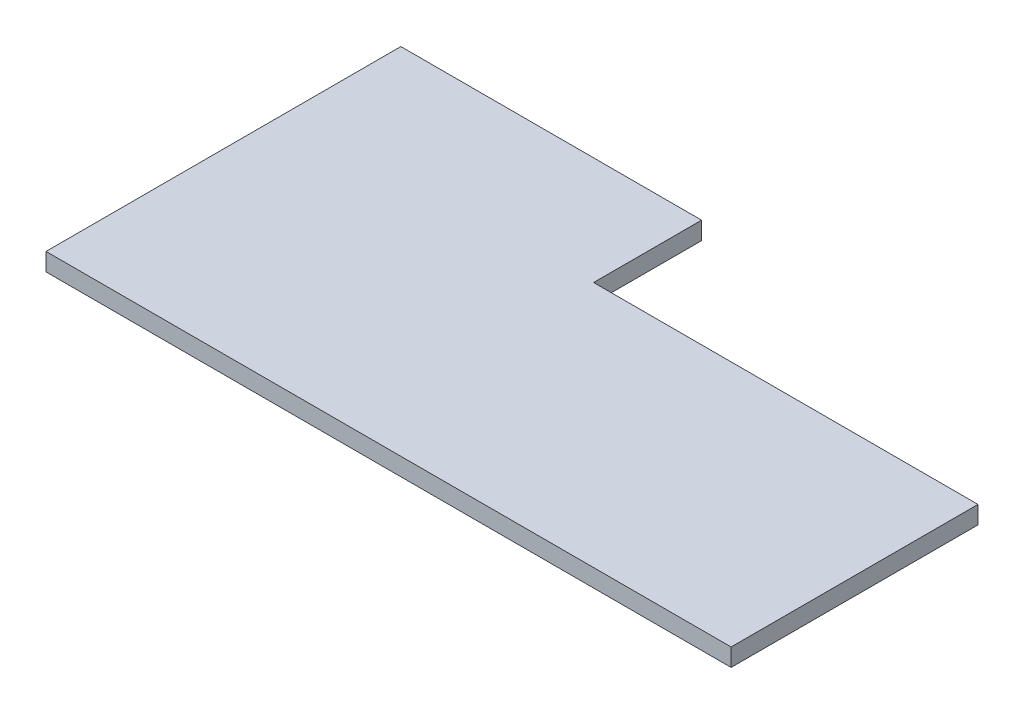
from build123d import *

# Parameters (mm, degrees)
BOSS_EXTRUDE1_DEPTH = 2.95


with BuildPart() as part:
    # Sketch1 → Boss-Extrude1 (new body)
    with BuildSketch(Plane(origin=(0, 0, 0), x_dir=(1, 0, 0), z_dir=(0, 1, 0))):
        Polygon((99.50336816, -3.682205931), (99.50336816, -44.732205931), (-14.40663184, -44.732205931), (-14.40663184, -0.732205931), (-14.40663184, 14.267794069), (35.59336816, 14.267794069), (35.59336816, -3.682205931), align=None)
    extrude(amount=BOSS_EXTRUDE1_DEPTH)


solid = part.part
